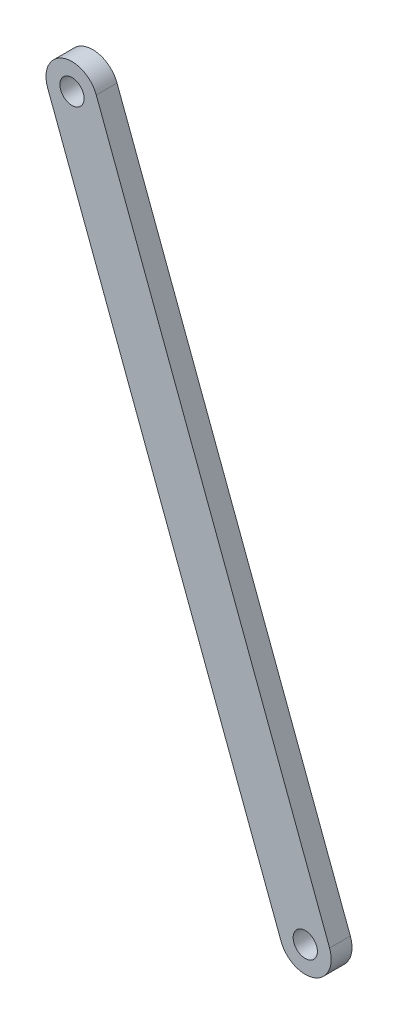
from build123d import *

# Parameters (mm, degrees)
SKETCH1_R   = 3.5
TIBYA_DEPTH = 6


with BuildPart() as part:
    # Sketch1 → Tibya (new body)
    with BuildSketch(Plane.XY):
        with BuildLine():
            Line((-60.403160777, -76.548284636), (7.022325478, -256.319816875))
            ThreePointArc((7.022325478, -256.319816875), (2.633808057, -265.975950409), (-7.022325478, -261.587432988))
            Line((-7.022325478, -261.587432988), (-74.447811733, -81.81590075))
            ThreePointArc((-74.447811733, -81.81590075), (-70.059294312, -72.159767215), (-60.403160777, -76.548284636))
        make_face()
        with Locations((-67.425486255, -79.182092693)):
            Circle(SKETCH1_R, mode=Mode.SUBTRACT)
        with Locations((0, -258.953624931)):
            Circle(SKETCH1_R, mode=Mode.SUBTRACT)
    extrude(amount=TIBYA_DEPTH)


solid = part.part
